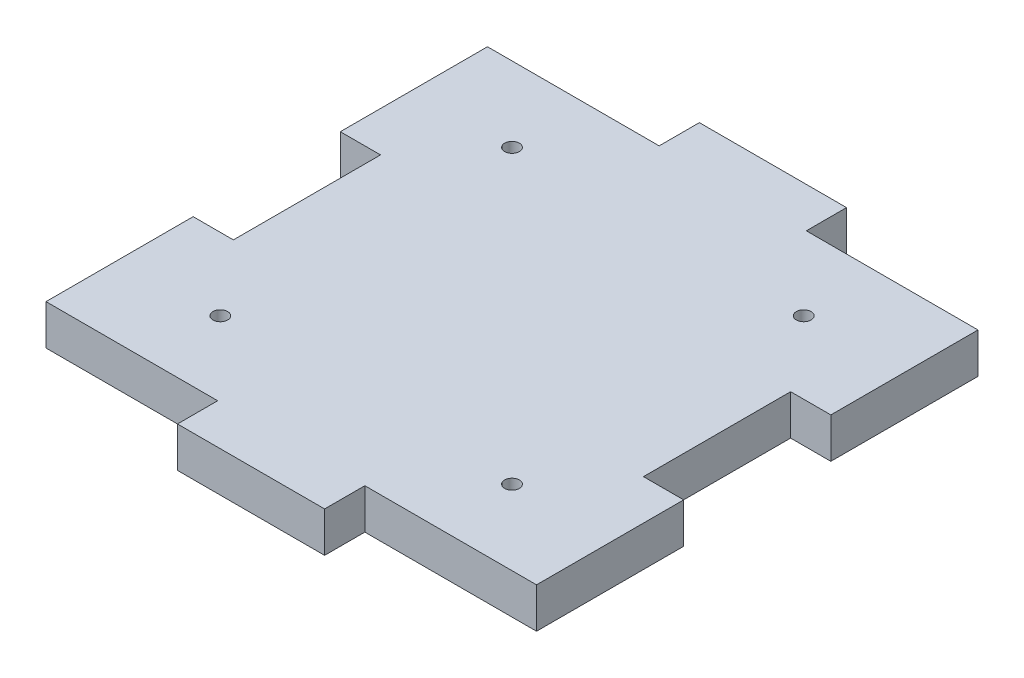
from build123d import *

# Parameters (mm, degrees)
SKETCH1_R           = 0.75
BOSS_EXTRUDE1_DEPTH = 4.1


with BuildPart() as part:
    # Sketch1 → Boss-Extrude1 (new body)
    with BuildSketch(Plane(origin=(0, 0, 0), x_dir=(1, 0, 0), z_dir=(0, 1, 0))):
        Polygon((0, 15), (4.1, 15), (4.1, 30), (0, 30), (0, 45), (17.5, 45), (17.5, 49.1), (32.5, 49.1), (32.5, 45), (50, 45), (50, 30), (45.9, 30), (45.9, 15), (50, 15), (50, 0), (32.5, 0), (32.5, -4.1), (17.5, -4.1), (17.5, 0), (0, 0), align=None)
        with Locations((10.133079926, 7.633079926)):
            Circle(SKETCH1_R, mode=Mode.SUBTRACT)
        with Locations((10.133079926, 37.366920074)):
            Circle(SKETCH1_R, mode=Mode.SUBTRACT)
        with Locations((39.866920074, 37.366920074)):
            Circle(SKETCH1_R, mode=Mode.SUBTRACT)
        with Locations((39.866920074, 7.633079926)):
            Circle(SKETCH1_R, mode=Mode.SUBTRACT)
    extrude(amount=BOSS_EXTRUDE1_DEPTH)


solid = part.part
